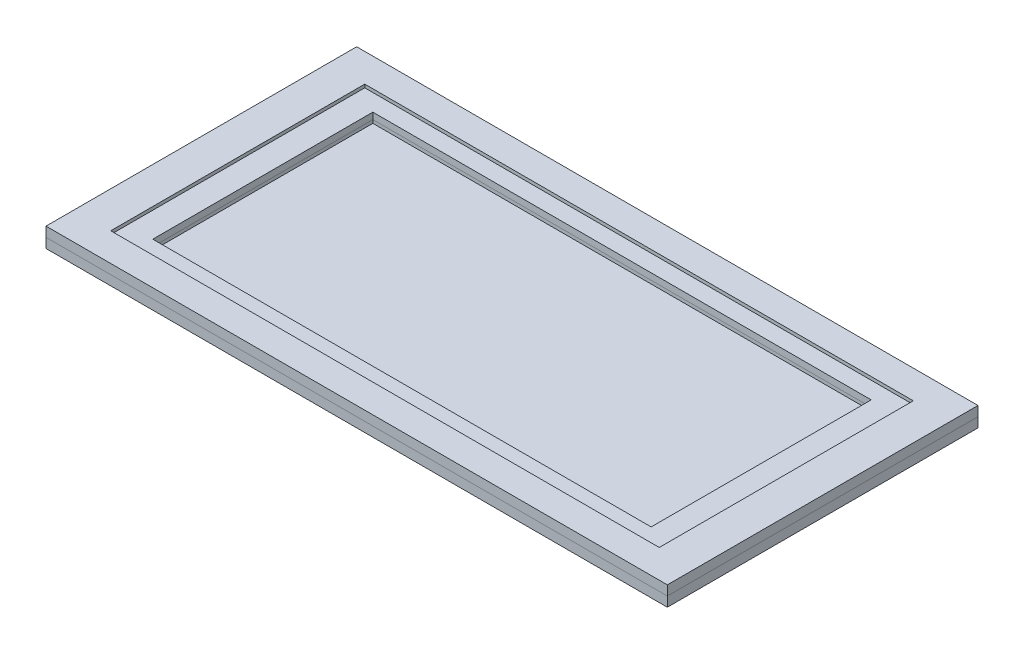
from build123d import *

# Parameters (mm, degrees)
SKETCH1_W        = 1219.2
SKETCH1_H        = 609.6
MDF_SLAB1_DEPTH  = 19.05
SKETCH2_W        = 1219.2
SKETCH2_H        = 609.6
MDF_SLAB2_DEPTH  = 19.05
SKETCH3_W        = 1076.325
SKETCH3_H        = 498.475
WINDOW_CUT_DEPTH = 6.35
SKETCH4_W        = 977.9
SKETCH4_H        = 431.8
MIRROR_CUT_DEPTH = 19.05


with BuildPart() as part:
    # Sketch1 → MDF_Slab1 (new body)
    with BuildSketch(Plane(origin=(0, 0, 0), x_dir=(1, 0, 0), z_dir=(0, 1, 0))):
        Rectangle(SKETCH1_W, SKETCH1_H)
    extrude(amount=MDF_SLAB1_DEPTH)


with BuildPart() as body_2:
    # Sketch2 → MDF_Slab2 (new body)
    with BuildSketch(Plane(origin=(0, 19.05, 0), x_dir=(1, 0, 0), z_dir=(0, 1, 0))):
        Rectangle(SKETCH2_W, SKETCH2_H)
    extrude(amount=MDF_SLAB2_DEPTH)

    # Sketch3 → Window_Cut (cut)
    with BuildSketch(Plane(origin=(0, 38.1, 0), x_dir=(1, 0, 0), z_dir=(0, 1, 0))):
        Rectangle(SKETCH3_W, SKETCH3_H)
    extrude(amount=-WINDOW_CUT_DEPTH, mode=Mode.SUBTRACT)


with BuildPart() as mirror_cut_tool:
    # Sketch4 → Mirror_Cut (new body)
    with BuildSketch(Plane(origin=(0, 31.75, 0), x_dir=(1, 0, 0), z_dir=(0, 1, 0))):
        Rectangle(SKETCH4_W, SKETCH4_H)
    extrude(amount=-MIRROR_CUT_DEPTH)


with BuildPart() as part_1:
    add(part.part)

    # Mirror_Cut: cut by mirror_cut_tool
    add(mirror_cut_tool.part, mode=Mode.SUBTRACT)


with BuildPart() as body_2_1:
    add(body_2.part)

    # Mirror_Cut: cut by mirror_cut_tool
    add(mirror_cut_tool.part, mode=Mode.SUBTRACT)


solid = Compound([part_1.part, body_2_1.part])
